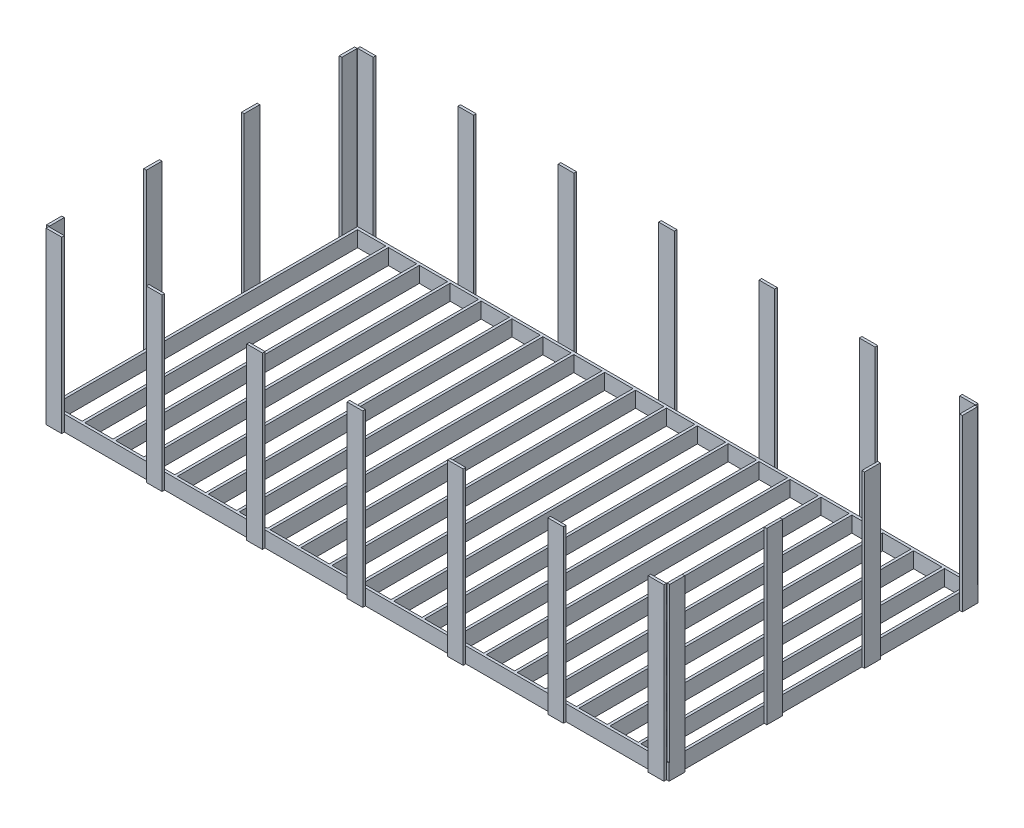
from build123d import *

# Parameters (mm, degrees)
SKETCH_2_W        = 6000
SKETCH_2_H        = 3000
SKETCH_2_W_2      = 274.4
SKETCH_2_H_2      = 2948.8
SKETCH_2_W_3      = 248.8
EXTRUDE_1_DEPTH   = 152.4
SKETCH_5_W        = 152.4
SKETCH_5_H        = 25.4
EXTRUDE_2_DEPTH   = 1652.4
SKETCH_6_W        = 25.4
SKETCH_6_H        = 152.4
EXTRUDE_5_DEPTH   = 152.4
EXTRUDE_5_2_DEPTH = 152.4
EXTRUDE_5_3_DEPTH = 152.4
EXTRUDE_5_4_DEPTH = 152.4
EXTRUDE_5_5_DEPTH = 152.4
EXTRUDE_5_6_DEPTH = 152.4
EXTRUDE_5_7_DEPTH = 152.4
EXTRUDE_5_8_DEPTH = 152.4
SKETCH_7_W        = 25.4
SKETCH_7_H        = 148.957449568
SKETCH_7_H_2      = 152.4
SKETCH_7_H_3      = 146.151439206
EXTRUDE_6_DEPTH   = 1500


with BuildPart() as part:
    # 草图2 → 凸台-拉伸1 (new body)
    with BuildSketch(Plane(origin=(0, 0, 0), x_dir=(1, 0, 0), z_dir=(0, 1, 0))):
        with Locations((3000, 1500)):
            Rectangle(SKETCH_2_W, SKETCH_2_H)
        with Locations((462.8, 1500)):
            Rectangle(SKETCH_2_W_2, SKETCH_2_H_2, mode=Mode.SUBTRACT)
        with Locations((162.8, 1500)):
            Rectangle(SKETCH_2_W_2, SKETCH_2_H_2, mode=Mode.SUBTRACT)
        with Locations((1062.8, 1500)):
            Rectangle(SKETCH_2_W_2, SKETCH_2_H_2, mode=Mode.SUBTRACT)
        with Locations((762.8, 1500)):
            Rectangle(SKETCH_2_W_2, SKETCH_2_H_2, mode=Mode.SUBTRACT)
        with Locations((2262.8, 1500)):
            Rectangle(SKETCH_2_W_2, SKETCH_2_H_2, mode=Mode.SUBTRACT)
        with Locations((1962.8, 1500)):
            Rectangle(SKETCH_2_W_2, SKETCH_2_H_2, mode=Mode.SUBTRACT)
        with Locations((1662.8, 1500)):
            Rectangle(SKETCH_2_W_2, SKETCH_2_H_2, mode=Mode.SUBTRACT)
        with Locations((1362.8, 1500)):
            Rectangle(SKETCH_2_W_2, SKETCH_2_H_2, mode=Mode.SUBTRACT)
        with Locations((4662.8, 1500)):
            Rectangle(SKETCH_2_W_2, SKETCH_2_H_2, mode=Mode.SUBTRACT)
        with Locations((4362.8, 1500)):
            Rectangle(SKETCH_2_W_2, SKETCH_2_H_2, mode=Mode.SUBTRACT)
        with Locations((4062.8, 1500)):
            Rectangle(SKETCH_2_W_2, SKETCH_2_H_2, mode=Mode.SUBTRACT)
        with Locations((3762.8, 1500)):
            Rectangle(SKETCH_2_W_2, SKETCH_2_H_2, mode=Mode.SUBTRACT)
        with Locations((3462.8, 1500)):
            Rectangle(SKETCH_2_W_2, SKETCH_2_H_2, mode=Mode.SUBTRACT)
        with Locations((3162.8, 1500)):
            Rectangle(SKETCH_2_W_2, SKETCH_2_H_2, mode=Mode.SUBTRACT)
        with Locations((2862.8, 1500)):
            Rectangle(SKETCH_2_W_2, SKETCH_2_H_2, mode=Mode.SUBTRACT)
        with Locations((2562.8, 1500)):
            Rectangle(SKETCH_2_W_2, SKETCH_2_H_2, mode=Mode.SUBTRACT)
        with Locations((5562.8, 1500)):
            Rectangle(SKETCH_2_W_2, SKETCH_2_H_2, mode=Mode.SUBTRACT)
        with Locations((5262.8, 1500)):
            Rectangle(SKETCH_2_W_2, SKETCH_2_H_2, mode=Mode.SUBTRACT)
        with Locations((4962.8, 1500)):
            Rectangle(SKETCH_2_W_2, SKETCH_2_H_2, mode=Mode.SUBTRACT)
        with Locations((5850, 1500)):
            Rectangle(SKETCH_2_W_3, SKETCH_2_H_2, mode=Mode.SUBTRACT)
    extrude(amount=EXTRUDE_1_DEPTH)

    # 草图5 → 凸台-拉伸2 (add)
    with BuildSketch(Plane(origin=(0, 0, 0), x_dir=(-1, 0, 0), z_dir=(0, -1, 0))):
        with Locations((-1050.8, 3012.5)):
            Rectangle(SKETCH_5_W, SKETCH_5_H)
        with Locations((-76.2, 3012.7)):
            Rectangle(SKETCH_5_W, SKETCH_5_H)
        with Locations((-2025.4, 3012.5)):
            Rectangle(SKETCH_5_W, SKETCH_5_H)
        with Locations((-3000, 3012.7)):
            Rectangle(SKETCH_5_W, SKETCH_5_H)
        with Locations((-3974.6, 3012.7)):
            Rectangle(SKETCH_5_W, SKETCH_5_H)
        with Locations((-4949.2, 3012.7)):
            Rectangle(SKETCH_5_W, SKETCH_5_H)
        with Locations((-5923.8, 3012.7)):
            Rectangle(SKETCH_5_W, SKETCH_5_H)
        with Locations((-5923.8, -12.7)):
            Rectangle(SKETCH_5_W, SKETCH_5_H)
        with Locations((-4949.2, -12.7)):
            Rectangle(SKETCH_5_W, SKETCH_5_H)
        with Locations((-3974.6, -12.7)):
            Rectangle(SKETCH_5_W, SKETCH_5_H)
        with Locations((-3000, -12.7)):
            Rectangle(SKETCH_5_W, SKETCH_5_H)
        with Locations((-2025.4, -12.5)):
            Rectangle(SKETCH_5_W, SKETCH_5_H)
        with Locations((-1050.8, -12.5)):
            Rectangle(SKETCH_5_W, SKETCH_5_H)
        with Locations((-76.2, -12.7)):
            Rectangle(SKETCH_5_W, SKETCH_5_H)
    extrude(amount=-EXTRUDE_2_DEPTH)



with BuildPart() as body_2:
    # 草图6 → 凸台-拉伸5 (new body)
    with BuildSketch(Plane.XZ):
        with Locations((-12.7, -76.2)):
            Rectangle(SKETCH_6_W, SKETCH_6_H)
    extrude(amount=-EXTRUDE_5_DEPTH)


with BuildPart() as body_3:
    # 草图6 → Extrude 5 2 (new body)
    with BuildSketch(Plane.XZ):
        with Locations((-12.7, -1025.4)):
            Rectangle(SKETCH_6_W, SKETCH_6_H)
    extrude(amount=-EXTRUDE_5_2_DEPTH)


with BuildPart() as body_4:
    # 草图6 → Extrude 5 3 (new body)
    with BuildSketch(Plane.XZ):
        with Locations((-12.7, -1974.6)):
            Rectangle(SKETCH_6_W, SKETCH_6_H)
    extrude(amount=-EXTRUDE_5_3_DEPTH)


with BuildPart() as body_5:
    # 草图6 → Extrude 5 4 (new body)
    with BuildSketch(Plane.XZ):
        with Locations((-12.7, -2923.8)):
            Rectangle(SKETCH_6_W, SKETCH_6_H)
    extrude(amount=-EXTRUDE_5_4_DEPTH)


with BuildPart() as body_6:
    # 草图6 → Extrude 5 5 (new body)
    with BuildSketch(Plane.XZ):
        with Locations((6012.7, -2923.8)):
            Rectangle(SKETCH_6_W, SKETCH_6_H)
    extrude(amount=-EXTRUDE_5_5_DEPTH)


with BuildPart() as body_7:
    # 草图6 → Extrude 5 6 (new body)
    with BuildSketch(Plane.XZ):
        with Locations((6012.7, -1974.6)):
            Rectangle(SKETCH_6_W, SKETCH_6_H)
    extrude(amount=-EXTRUDE_5_6_DEPTH)


with BuildPart() as body_8:
    # 草图6 → Extrude 5 7 (new body)
    with BuildSketch(Plane.XZ):
        with Locations((6012.7, -1025.4)):
            Rectangle(SKETCH_6_W, SKETCH_6_H)
    extrude(amount=-EXTRUDE_5_7_DEPTH)


with BuildPart() as body_9:
    # 草图6 → Extrude 5 8 (new body)
    with BuildSketch(Plane.XZ):
        with Locations((6012.7, -76.2)):
            Rectangle(SKETCH_6_W, SKETCH_6_H)
    extrude(amount=-EXTRUDE_5_8_DEPTH)


with BuildPart() as part_1:
    add(part.part)

    add(body_2.part)  # 凸台-拉伸6 merges body 2

    add(body_3.part)  # 凸台-拉伸6 merges body 3

    add(body_4.part)  # 凸台-拉伸6 merges body 4

    add(body_5.part)  # 凸台-拉伸6 merges body 5

    add(body_6.part)  # 凸台-拉伸6 merges body 6

    add(body_7.part)  # 凸台-拉伸6 merges body 7

    add(body_8.part)  # 凸台-拉伸6 merges body 8

    add(body_9.part)  # 凸台-拉伸6 merges body 9
    # 草图7 → 凸台-拉伸6 (add)
    with BuildSketch(Plane(origin=(0, 152.4, 0), x_dir=(1, 0, 0), z_dir=(0, 1, 0))):
        with Locations((-12.7, 2922.078724784)):
            Rectangle(SKETCH_7_W, SKETCH_7_H)
        with Locations((-12.7, 1974.6)):
            Rectangle(SKETCH_7_W, SKETCH_7_H_2)
        with Locations((-12.7, 1025.4)):
            Rectangle(SKETCH_7_W, SKETCH_7_H_2)
        with Locations((-12.7, 79.324280397)):
            Rectangle(SKETCH_7_W, SKETCH_7_H_3)
        with Locations((6012.7, 2922.078724784)):
            Rectangle(SKETCH_7_W, SKETCH_7_H)
        with Locations((6012.7, 1974.6)):
            Rectangle(SKETCH_7_W, SKETCH_7_H_2)
        with Locations((6012.7, 1025.4)):
            Rectangle(SKETCH_7_W, SKETCH_7_H_2)
        with Locations((6012.7, 79.324280397)):
            Rectangle(SKETCH_7_W, SKETCH_7_H_3)
    extrude(amount=EXTRUDE_6_DEPTH)


solid = part_1.part
